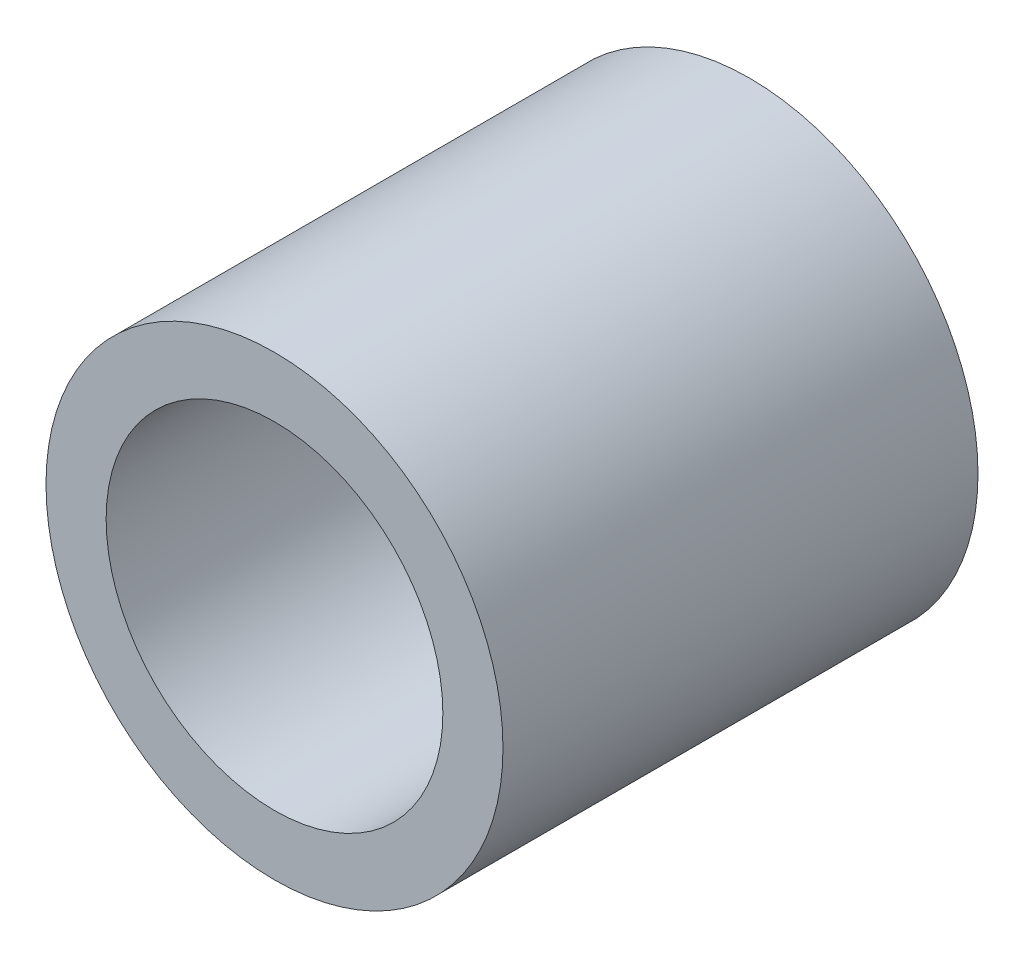
from build123d import *

# Parameters (mm, degrees)
SKETCH1_R           = 4.826
SKETCH1_R_2         = 3.556
BOSS_EXTRUDE1_DEPTH = 10.033


with BuildPart() as part:
    # Sketch1 → Boss-Extrude1 (new body)
    with BuildSketch(Plane.XY):
        Circle(SKETCH1_R)
        Circle(SKETCH1_R_2, mode=Mode.SUBTRACT)
    extrude(amount=BOSS_EXTRUDE1_DEPTH)


solid = part.part
